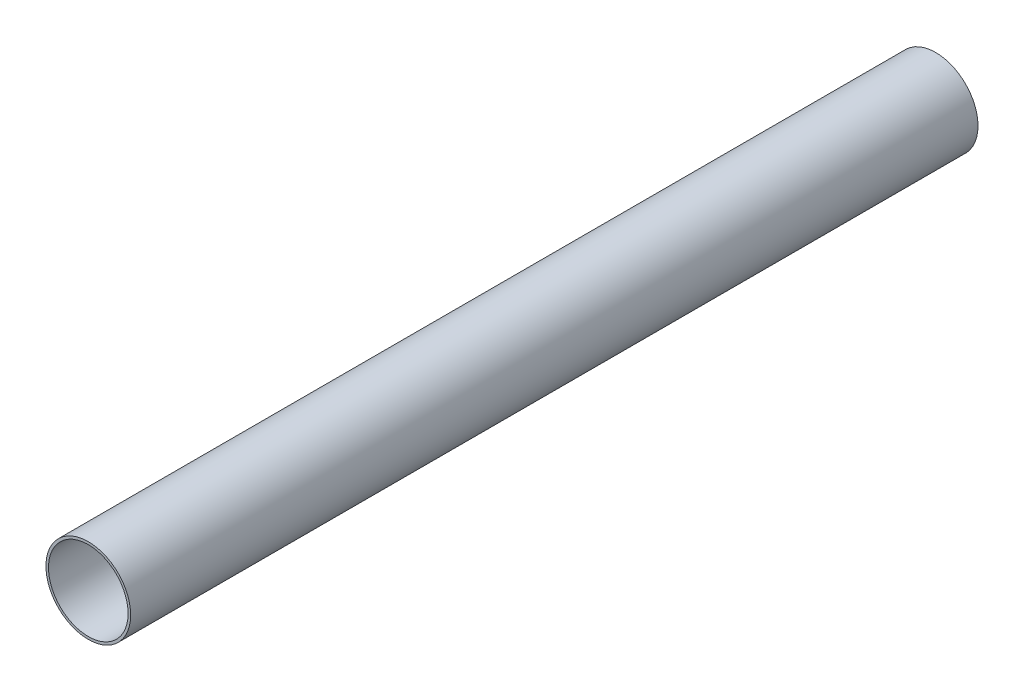
from build123d import *

# Parameters (mm, degrees)
SKETCH1_R           = 25
SKETCH1_R_2         = 23.5
BOSS_EXTRUDE1_DEPTH = 500


with BuildPart() as part:
    # Sketch1 → Boss-Extrude1 (new body)
    with BuildSketch(Plane.XY):
        Circle(SKETCH1_R)
        Circle(SKETCH1_R_2, mode=Mode.SUBTRACT)
    extrude(amount=BOSS_EXTRUDE1_DEPTH)


solid = part.part
